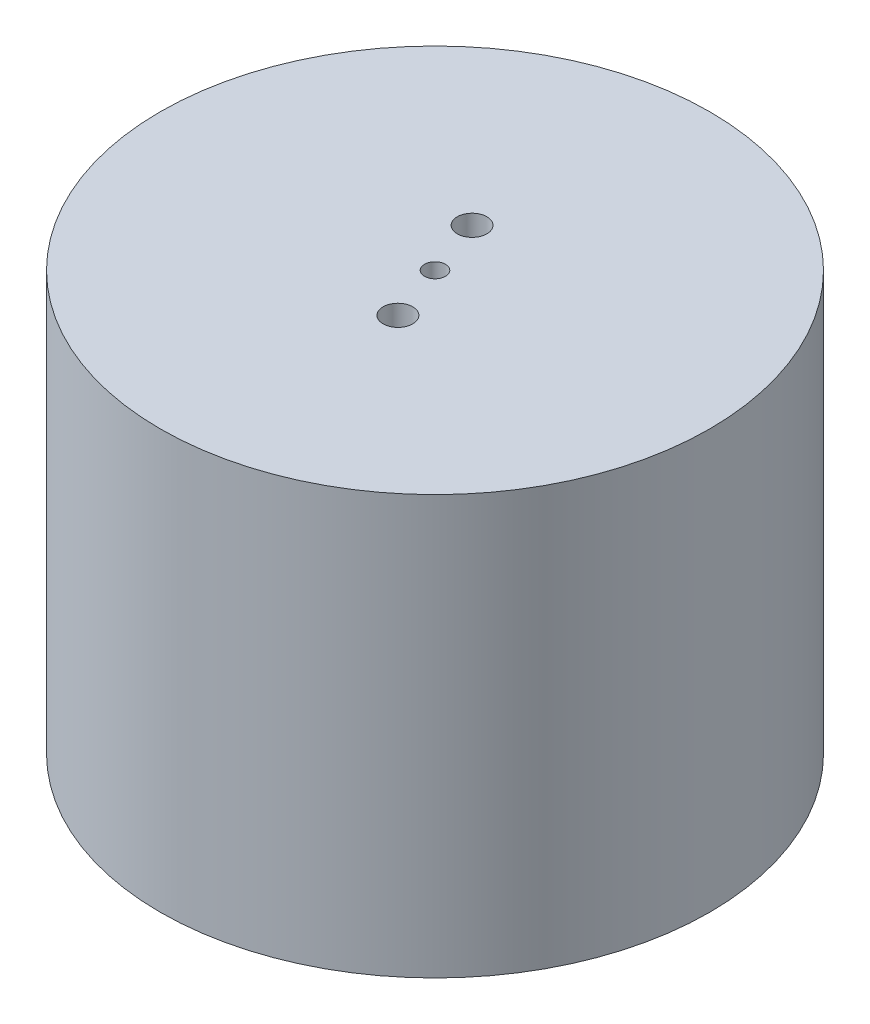
from build123d import *

# Parameters (mm, degrees)
SKETCH4_R                = 31.5
BOSS_EXTRUDE2_DEPTH      = 48
SKETCH3_R                = 26.5
CUT_EXTRUDE1_DEPTH       = 43
M3_CLEARANCE_HOLE1_D     = 3.4
M3_CLEARANCE_HOLE1_DEPTH = 50
M3_CLEARANCE_HOLE1_TIP   = 1.021463052
SKETCH10_R               = 1.2
CUT_EXTRUDE2_DEPTH       = 10


with BuildPart() as part:
    # Sketch4 → Boss-Extrude2 (new body)
    with BuildSketch(Plane(origin=(0, 0, 0), x_dir=(1, 0, 0), z_dir=(0, 1, 0))):
        Circle(SKETCH4_R)
    extrude(amount=BOSS_EXTRUDE2_DEPTH)

    # Sketch3 → Cut-Extrude1 (cut)
    with BuildSketch(Plane(origin=(0, 0, 0), x_dir=(1, 0, 0), z_dir=(0, 1, 0))):
        Circle(SKETCH3_R)
    extrude(amount=CUT_EXTRUDE1_DEPTH, mode=Mode.SUBTRACT)

    # M3 Clearance Hole1
    with Locations(Plane(origin=(0, 48, 0), x_dir=(1, 0, 0), z_dir=(0, 1, 0))):
        with Locations((-2.345047045, 6.595510166), (2.345047045, -6.595510166)):
            Hole(M3_CLEARANCE_HOLE1_D / 2, depth=M3_CLEARANCE_HOLE1_DEPTH)
            with Locations((0, 0, -(M3_CLEARANCE_HOLE1_DEPTH + M3_CLEARANCE_HOLE1_TIP / 2))):  # 118° drill point
                Cone(0, M3_CLEARANCE_HOLE1_D / 2, M3_CLEARANCE_HOLE1_TIP, mode=Mode.SUBTRACT)

    # Sketch10 → Cut-Extrude2 (cut)
    with BuildSketch(Plane(origin=(0, 48, 0), x_dir=(1, 0, 0), z_dir=(0, 1, 0))):
        Circle(SKETCH10_R)
    extrude(amount=-CUT_EXTRUDE2_DEPTH, mode=Mode.SUBTRACT)


solid = part.part
